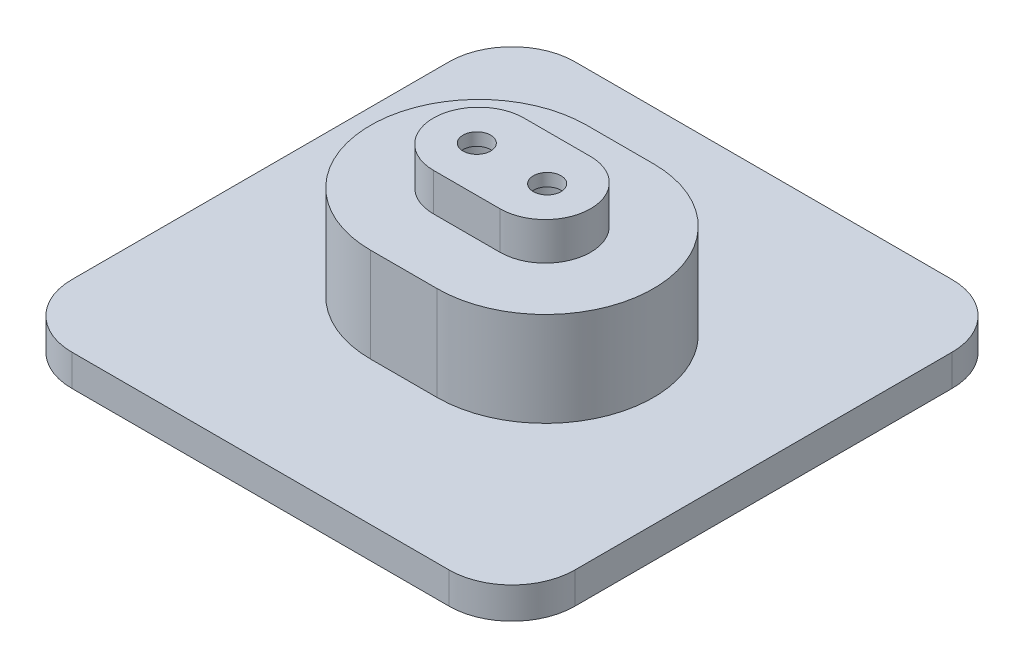
from build123d import *

# Parameters (mm, degrees)
BOSS_EXTRUDE1_DEPTH = 5
BOSS_EXTRUDE2_DEPTH = 15
BOSS_EXTRUDE3_DEPTH = 6
SKETCH6_R           = 2.2
CUT_EXTRUDE1_DEPTH  = 27
SKETCH7_R           = 4.1
CUT_EXTRUDE2_DEPTH  = 24


with BuildPart() as part:
    # Sketch1 → Boss-Extrude1 (new body)
    with BuildSketch(Plane(origin=(0, 0, 0), x_dir=(1, 0, 0), z_dir=(0, 1, 0))):
        with BuildLine():
            Line((30, -40), (-30, -40))
            ThreePointArc((-30, -40), (-37.071067812, -37.071067812), (-40, -30))
            Line((-40, -30), (-40, 30))
            ThreePointArc((-40, 30), (-37.071067812, 37.071067812), (-30, 40))
            Line((-30, 40), (30, 40))
            ThreePointArc((30, 40), (37.071067812, 37.071067812), (40, 30))
            Line((40, 30), (40, -30))
            ThreePointArc((40, -30), (37.071067812, -37.071067812), (30, -40))
        make_face()
    extrude(amount=BOSS_EXTRUDE1_DEPTH)

    # Sketch4 → Boss-Extrude2 (add)
    with BuildSketch(Plane(origin=(0, 5, 0), x_dir=(1, 0, 0), z_dir=(0, 1, 0))):
        with BuildLine():
            Line((-5.29954084, -17.20045916), (5.29954084, -17.20045916))
            ThreePointArc((5.29954084, -17.20045916), (22.5, 0), (5.29954084, 17.20045916))
            Line((5.29954084, 17.20045916), (-5.29954084, 17.20045916))
            ThreePointArc((-5.29954084, 17.20045916), (-22.5, 0), (-5.29954084, -17.20045916))
        make_face()
    extrude(amount=BOSS_EXTRUDE2_DEPTH)

    # Sketch5 → Boss-Extrude3 (add)
    with BuildSketch(Plane(origin=(0, 20, 0), x_dir=(1, 0, 0), z_dir=(0, 1, 0))):
        with BuildLine():
            Line((-5.29954084, -7.20045916), (5.29954084, -7.20045916))
            ThreePointArc((5.29954084, -7.20045916), (12.5, 0), (5.29954084, 7.20045916))
            Line((5.29954084, 7.20045916), (-5.29954084, 7.20045916))
            ThreePointArc((-5.29954084, 7.20045916), (-12.5, 0), (-5.29954084, -7.20045916))
        make_face()
    extrude(amount=BOSS_EXTRUDE3_DEPTH)

    # Sketch6 → Cut-Extrude1 (cut)
    with BuildSketch(Plane(origin=(0, 26, 0), x_dir=(1, 0, 0), z_dir=(0, 1, 0))):
        with Locations((-5.595, 0)):
            Circle(SKETCH6_R)
        with Locations((5.595, 0)):
            Circle(SKETCH6_R)
    extrude(amount=-CUT_EXTRUDE1_DEPTH, mode=Mode.SUBTRACT)

    # Sketch7 → Cut-Extrude2 (cut)
    with BuildSketch(Plane.XZ):
        with Locations((5.595, 0)):
            Circle(SKETCH7_R)
        with Locations((-5.595, 0)):
            Circle(SKETCH7_R)
    extrude(amount=-CUT_EXTRUDE2_DEPTH, mode=Mode.SUBTRACT)


solid = part.part
